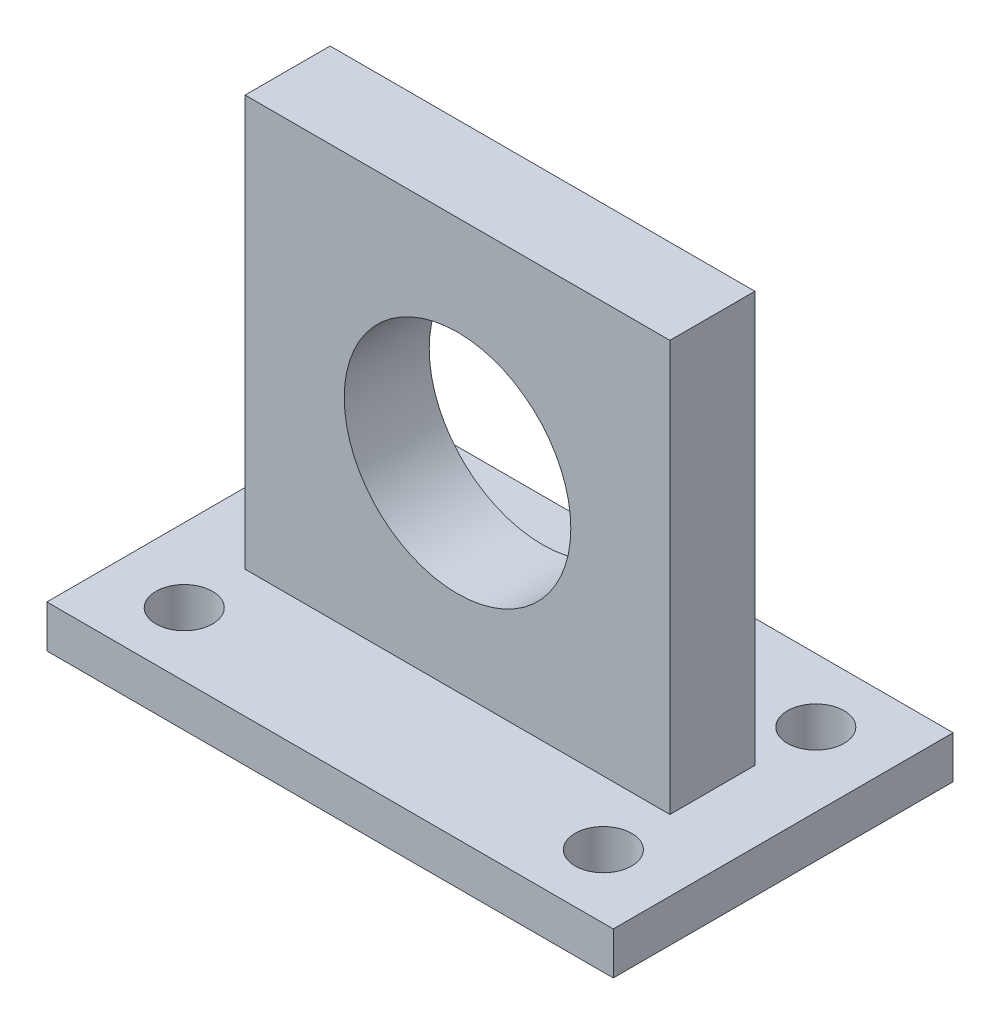
from build123d import *

# Parameters (mm, degrees)
SKETCH_1_W          = 40
SKETCH_1_H          = 24
SKETCH_1_R          = 2
EXTRUDE_1_DEPTH     = 3
SKETCH_2_W          = 20
SKETCH_2_H          = 6
EXTRUDE_2_DEPTH     = 25
SKETCH_3_R          = 7.9375
CUT_EXTRUDE_1_DEPTH = 10
EXTRUDE_4_DEPTH     = 6
SKETCH_5_R          = 8
CUT_EXTRUDE_2_DEPTH = 6


with BuildPart() as part:
    # 草图1 → 凸台-拉伸1 (new body)
    with BuildSketch(Plane(origin=(0, 0, 0), x_dir=(1, 0, 0), z_dir=(0, 1, 0))):
        Rectangle(SKETCH_1_W, SKETCH_1_H)
        with Locations((-14.8, -7.5)):
            Circle(SKETCH_1_R, mode=Mode.SUBTRACT)
        with Locations((14.8, -7.5)):
            Circle(SKETCH_1_R, mode=Mode.SUBTRACT)
        with Locations((-14.8, 7.5)):
            Circle(SKETCH_1_R, mode=Mode.SUBTRACT)
        with Locations((14.8, 7.5)):
            Circle(SKETCH_1_R, mode=Mode.SUBTRACT)
    extrude(amount=EXTRUDE_1_DEPTH)

    # 草图2 → 凸台-拉伸2 (add)
    with BuildSketch(Plane(origin=(0, 3, 0), x_dir=(1, 0, 0), z_dir=(0, 1, 0))):
        Rectangle(SKETCH_2_W, SKETCH_2_H)
    extrude(amount=EXTRUDE_2_DEPTH)

    # 草图3 → 切除-拉伸1 (cut)
    with BuildSketch(Plane.XY.offset(3)):
        with Locations((0, 17)):
            Circle(SKETCH_3_R)
    extrude(amount=-CUT_EXTRUDE_1_DEPTH, mode=Mode.SUBTRACT)

    # 草图4 → 凸台-拉伸4 (add)
    with BuildSketch(Plane.XY.offset(3)):
        Polygon((-15, 32), (-15, 3), (-10, 3), (-10, 28), (10, 28), (10, 3), (15, 3), (15, 32), align=None)
    extrude(amount=-EXTRUDE_4_DEPTH)

    # 草图5 → 切除-拉伸2 (cut)
    with BuildSketch(Plane.XY.offset(3)):
        with Locations((0, 17)):
            Circle(SKETCH_5_R)
    extrude(amount=-CUT_EXTRUDE_2_DEPTH, mode=Mode.SUBTRACT)


solid = part.part
